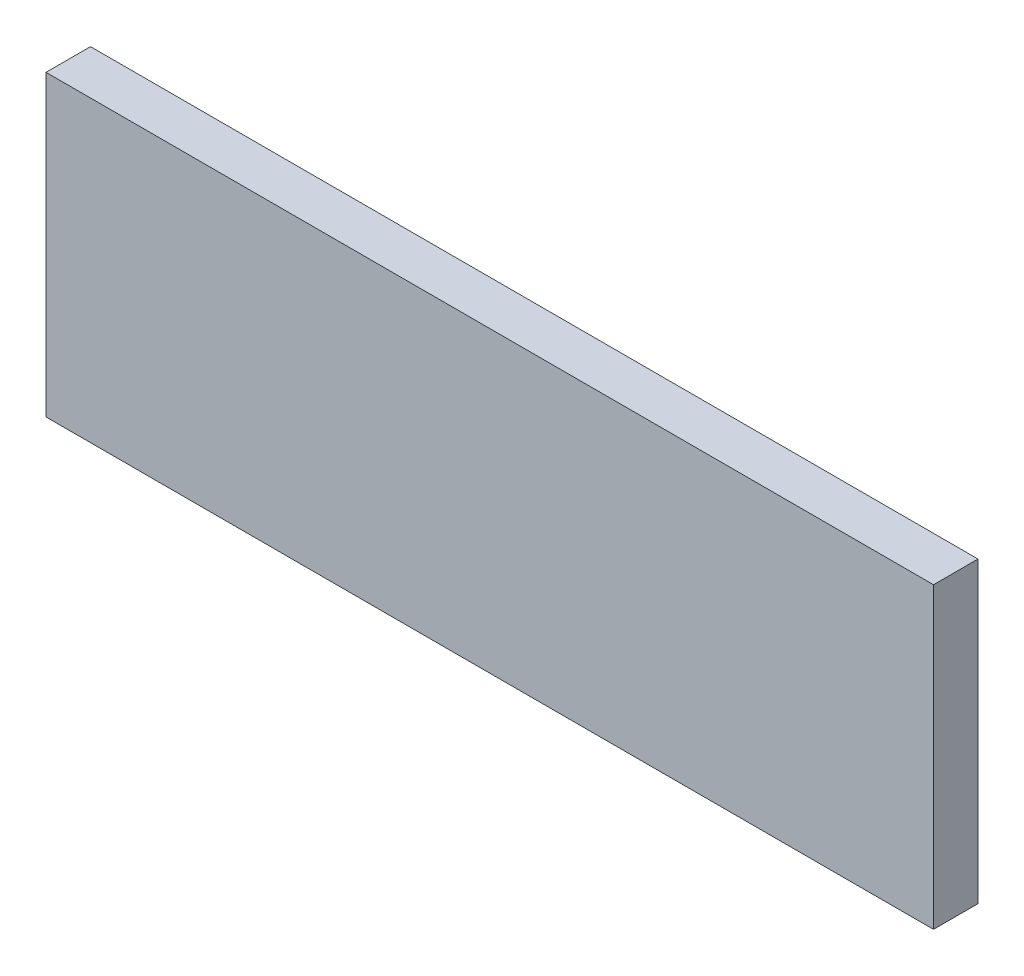
from build123d import *

# Parameters (mm, degrees)
SKETCH1_W                   = 190
SKETCH1_H                   = 63.9
BOSS_EXTRUDE1_DEPTH         = 9.525
TAP_DRILL_FOR_M4_TAP1_D     = 3.3
TAP_DRILL_FOR_M4_TAP1_DEPTH = 12.7
TAP_DRILL_FOR_M4_TAP1_TIP   = 0.991420021


with BuildPart() as part:
    # Sketch1 → Boss-Extrude1 (new body)
    with BuildSketch(Plane.XY):
        Rectangle(SKETCH1_W, SKETCH1_H)
    extrude(amount=BOSS_EXTRUDE1_DEPTH)

    # Tap Drill for M4 Tap1
    with Locations(Plane(origin=(0, -31.95, 0), x_dir=(-1, 0, 0), z_dir=(0, -1, 0))):
        with Locations((-71.25, -4.7625), (0, -4.7625), (71.25, -4.7625)):
            Hole(TAP_DRILL_FOR_M4_TAP1_D / 2, depth=TAP_DRILL_FOR_M4_TAP1_DEPTH)
            with Locations((0, 0, -(TAP_DRILL_FOR_M4_TAP1_DEPTH + TAP_DRILL_FOR_M4_TAP1_TIP / 2))):  # 118° drill point
                Cone(0, TAP_DRILL_FOR_M4_TAP1_D / 2, TAP_DRILL_FOR_M4_TAP1_TIP, mode=Mode.SUBTRACT)


solid = part.part
